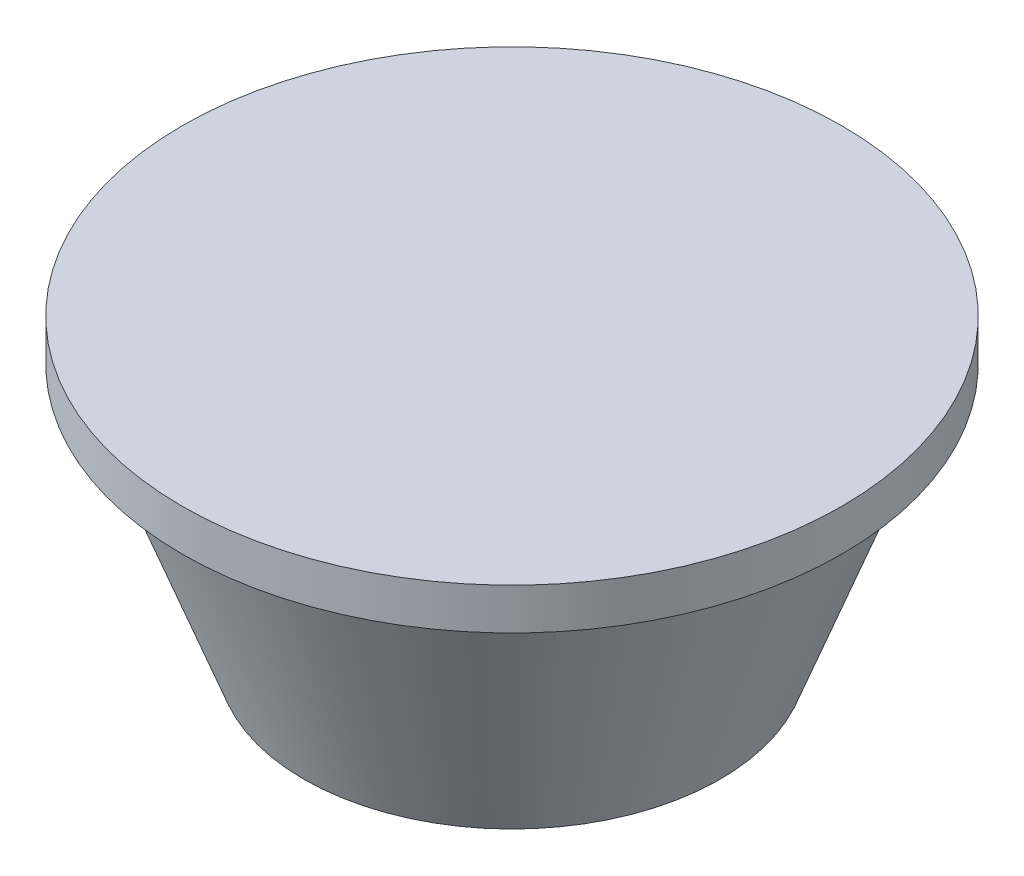
from build123d import *


with BuildPart() as part:
    # Sketch1 → Revolve1 (revolve)
    with BuildSketch(Plane(origin=(0, 0, 0), x_dir=(0, 0, -1), z_dir=(1, 0, 0))):
        Polygon((0, 2), (0, 0), (30, 0), (45, 40), (42.863999064, 40), (28.613999064, 2), align=None)
    revolve(axis=Axis((0, 2, 0), (0, -1, 0)))


with BuildPart() as body_2:
    # Sketch2 → Revolve2 (revolve)
    with BuildSketch(Plane(origin=(0, 0, 0), x_dir=(0, 0, -1), z_dir=(1, 0, 0))):
        Polygon((47.5, 42.8), (0, 42.8), (0, 40.3), (45.6, 40.3), (44.3, 36.833333333), (47.5, 36.833333333), align=None)
    revolve(axis=Axis((0, 40.3, 0), (0, 1, 0)))


solid = Compound([part.part, body_2.part])
